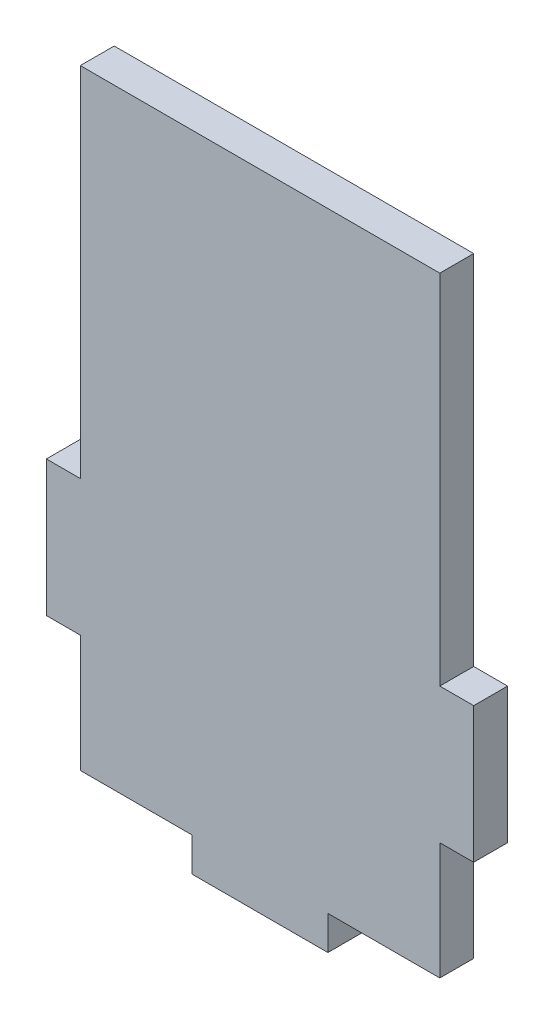
from build123d import *

# Parameters (mm, degrees)
BOSS_EXTRUDE1_DEPTH = 5


with BuildPart() as part:
    # Sketch1 → Boss-Extrude1 (new body)
    with BuildSketch(Plane.XY):
        Polygon((26.5, -27.724861484), (26.5, -45), (10, -45), (10, -50), (-10, -50), (-10.046380259, -45), (-26.5, -45), (-26.5, -27.724861484), (-31.5, -27.724861484), (-31.5, -7.724861484), (-26.5, -7.724861484), (-26.5, 45), (26.5, 45), (26.5, -7.724861484), (31.5, -7.724861484), (31.5, -27.724861484), align=None)
    extrude(amount=BOSS_EXTRUDE1_DEPTH)


solid = part.part
